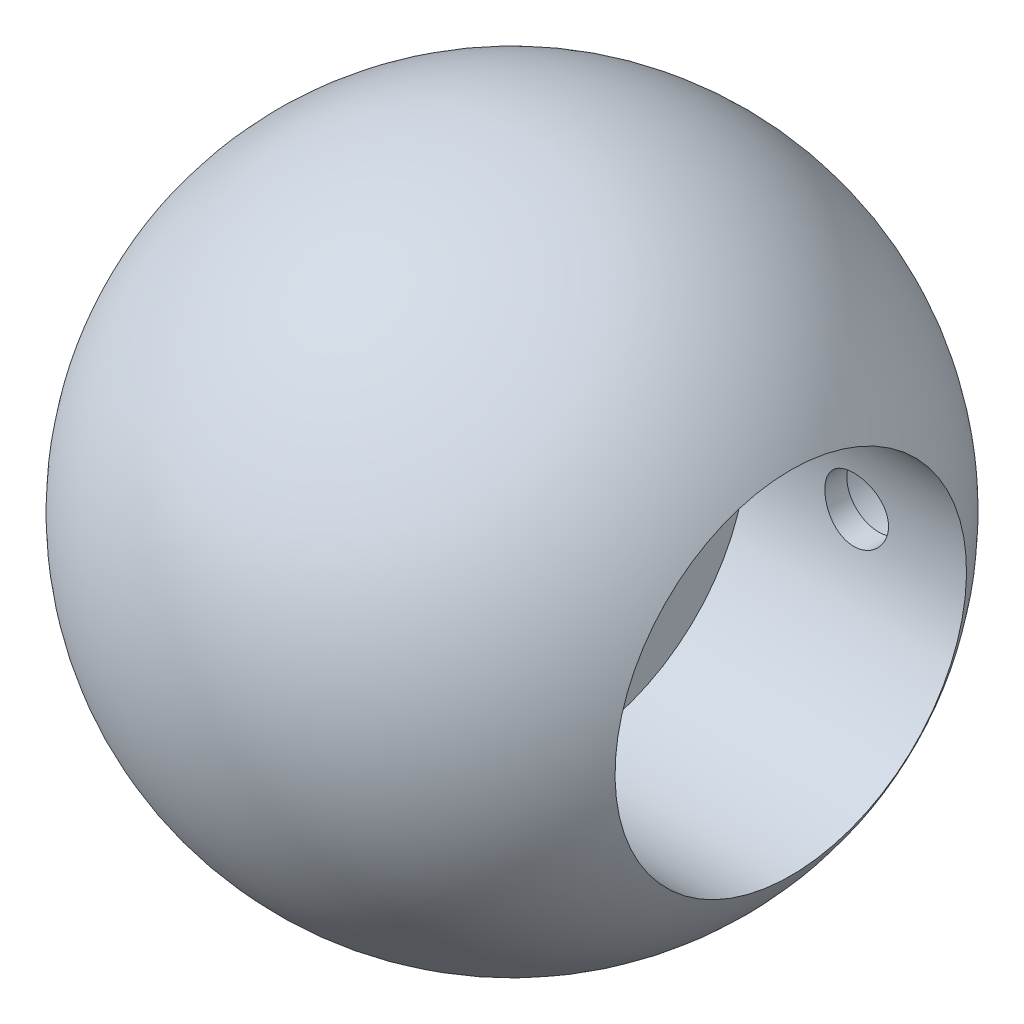
from build123d import *

# Parameters (mm, degrees)
SKETCH_2_R               = 8
CUT_EXTRUDE_1_DEPTH      = 10
SKETCH_3_R               = 1.45
CUT_EXTRUDE_4_DEPTH      = 11
CUT_EXTRUDE_4_DEPTH_BACK = 9
CUT_EXTRUDE_5_REACH      = 8
SKETCH_5_R               = 2.55


with BuildPart() as part:
    # 草图1 → 旋转8 (revolve)
    with BuildSketch(Plane.XY):
        with BuildLine():
            Line((12.68857754, 8), (12.68857754, 0))
            Line((12.68857754, 0), (-15, 0))
            ThreePointArc((-15, 0), (-4.163612428, 14.410563193), (12.68857754, 8))
        make_face()
    revolve(axis=Axis((12.68857754, 0, 0), (-1, 0, 0)))

    # 草图2 → 切除-拉伸1 (cut)
    with BuildSketch(Plane(origin=(12.68857754, 0, 0), x_dir=(0, 0, -1), z_dir=(1, 0, 0))):
        Circle(SKETCH_2_R)
    extrude(amount=-CUT_EXTRUDE_1_DEPTH, mode=Mode.SUBTRACT)

    # 草图3 → 切除-拉伸4 (cut, two sides)
    with BuildSketch(Plane.XY) as cut_extrude_4_sk:
        with Locations((7.68857754, 0)):
            Circle(SKETCH_3_R)
    extrude(amount=CUT_EXTRUDE_4_DEPTH, mode=Mode.SUBTRACT)
    extrude(cut_extrude_4_sk.sketch, amount=-CUT_EXTRUDE_4_DEPTH_BACK, mode=Mode.SUBTRACT)

    # 草图5 → 切除-拉伸5 (cut, up to next)
    with BuildSketch(Plane.XY.offset(-9), mode=Mode.PRIVATE) as cut_extrude_5_sk1:
        with Locations((7.68857754, 0)):
            Circle(SKETCH_5_R)
    cut_extrude_5_tool1 = extrude(cut_extrude_5_sk1.sketch, amount=-CUT_EXTRUDE_5_REACH, mode=Mode.PRIVATE) & part.part
    add(cut_extrude_5_tool1.solids().sort_by_distance((7.688578, 0, -9))[0], mode=Mode.SUBTRACT)


solid = part.part
